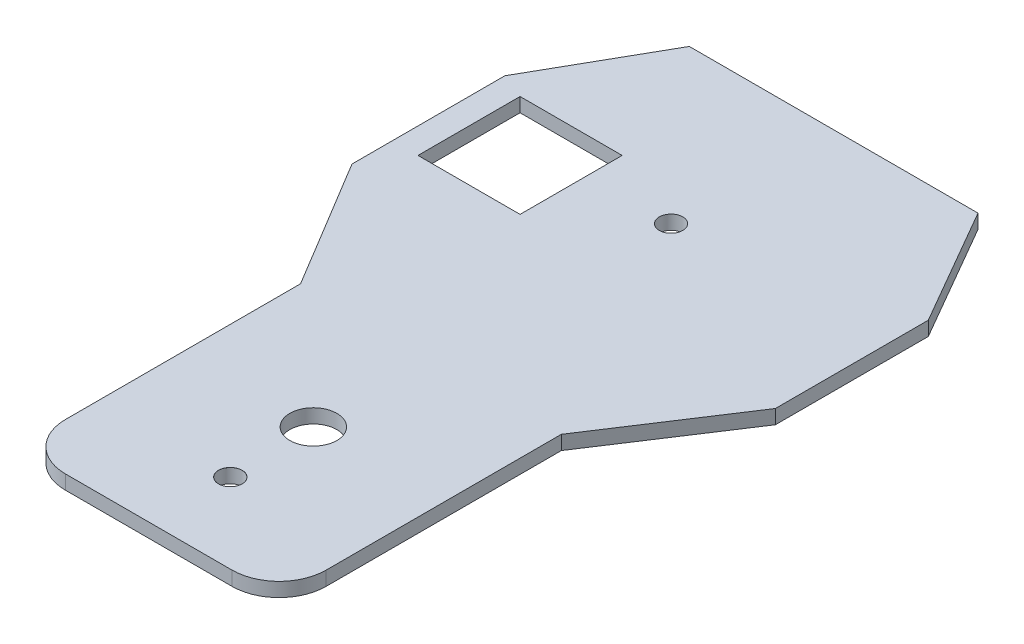
from build123d import *

# Parameters (mm, degrees)
BOSS_EXTRUDE1_DEPTH              = 6
FILLET1_R                        = 20
FILLET2_R                        = 20
SKETCH30_R                       = 10
CUT_EXTRUDE44_DEPTH              = 7
CUT_EXTRUDE44_DEPTH_BACK         = 1
SKETCH31_R                       = 5
CUT_EXTRUDE45_DEPTH              = 10
BODY_MOVE_COPY3_ANGLE            = 90
BODY_MOVE_COPY4_ANGLE            = 180
F_10_0MM_DOWEL_HOLE1_D           = 10
F_10_0MM_DOWEL_HOLE1_DEPTH       = 50
F_10_0MM_DOWEL_HOLE1_CSINK_D     = 10.05
F_10_0MM_DOWEL_HOLE1_CSINK_ANGLE = 90
F_10_0MM_DOWEL_HOLE1_TIP         = 3.004303095
SKETCH35_W                       = 43.4
SKETCH35_H                       = 43.4
CUT_EXTRUDE46_DEPTH              = 200


with BuildPart() as part:
    # Sketch6 → Boss-Extrude1 (new body)
    with BuildSketch(Plane.XY):
        Polygon((-61.363636364, 0), (61.363636364, 0), (90.231149823, -50), (90.231149823, -115), (54.237430104, -170), (54.237430104, -290), (-56.622130409, -290), (-56.622130409, -170), (-89.768850177, -115), (-89.768850177, -50), align=None)
    extrude(amount=BOSS_EXTRUDE1_DEPTH)

    # Fillet1
    fillet1_edges = [part.edges().sort_by_distance(p)[0] for p in [
        (54.237430104, -290, 3),
    ]]
    fillet(fillet1_edges, radius=FILLET1_R)

    # Fillet2
    fillet2_edges = [part.edges().sort_by_distance(p)[0] for p in [
        (-56.622130409, -290, 3),
    ]]
    fillet(fillet2_edges, radius=FILLET2_R)

    # Sketch30 → Cut-Extrude44 (cut, two sides)
    with BuildSketch(Plane.XY) as cut_extrude44_sk:
        with Locations((-1.192350152, -220)):
            Circle(SKETCH30_R)
    extrude(amount=CUT_EXTRUDE44_DEPTH, mode=Mode.SUBTRACT)
    extrude(cut_extrude44_sk.sketch, amount=-CUT_EXTRUDE44_DEPTH_BACK, mode=Mode.SUBTRACT)

    # Sketch31 → Cut-Extrude45 (cut)
    with BuildSketch(Plane.XY.offset(6)):
        with Locations((0, -69.133646514)):
            Circle(SKETCH31_R)
    extrude(amount=-CUT_EXTRUDE45_DEPTH, mode=Mode.SUBTRACT)


with BuildPart() as part_1:
    # Body-Move/Copy3: moved
    add(part.part.rotate(Axis((0, -121.936798964, -1), (1, 0, 0)), BODY_MOVE_COPY3_ANGLE))


with BuildPart() as part_2:
    # Body-Move/Copy4: moved
    add(part_1.part.rotate(Axis((0, -111.936798964, -21), (1, 0, 0)), BODY_MOVE_COPY4_ANGLE))


with BuildPart() as part_3:
    # Body-Move/Copy5: moved
    add(part_2.part.moved(Location((52.144140366, 0, 0))))

    # Ø10.0mm Dowel Hole1
    with Locations(Plane(origin=(0, -94.936798964, 0), x_dir=(1, 0, 0), z_dir=(0, 1, 0))):
        with Locations((51.761395867, -93.178073243)):
            CounterSinkHole(F_10_0MM_DOWEL_HOLE1_D / 2, F_10_0MM_DOWEL_HOLE1_CSINK_D / 2, depth=F_10_0MM_DOWEL_HOLE1_DEPTH, counter_sink_angle=F_10_0MM_DOWEL_HOLE1_CSINK_ANGLE)
            with Locations((0, 0, -(F_10_0MM_DOWEL_HOLE1_DEPTH + F_10_0MM_DOWEL_HOLE1_TIP / 2))):  # 118° drill point
                Cone(0, F_10_0MM_DOWEL_HOLE1_D / 2, F_10_0MM_DOWEL_HOLE1_TIP, mode=Mode.SUBTRACT)

    # Sketch35 → Cut-Extrude46 (cut)
    with BuildSketch(Plane(origin=(0, 0, 0), x_dir=(1, 0, 0), z_dir=(0, 1, 0))):
        with Locations((-5.062927598, 86.826541805)):
            Rectangle(SKETCH35_W, SKETCH35_H)
    extrude(amount=-CUT_EXTRUDE46_DEPTH, mode=Mode.SUBTRACT)


solid = part_3.part
